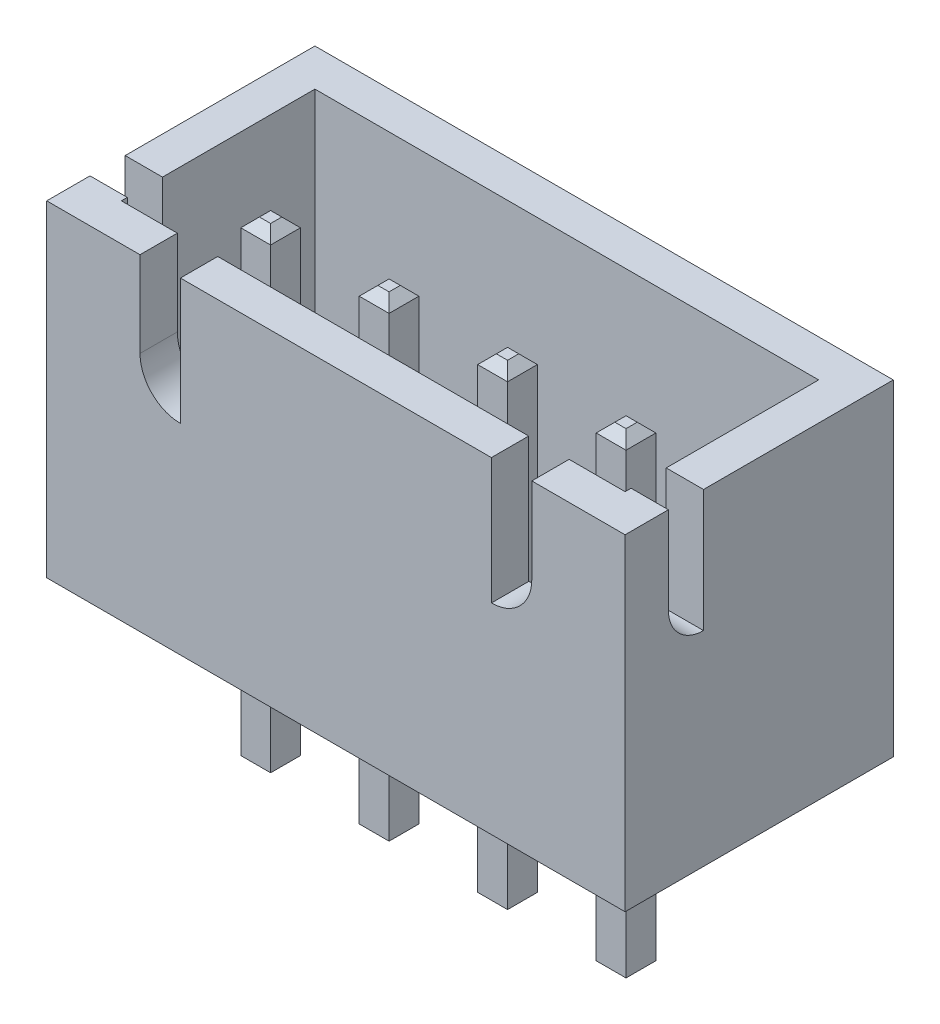
from build123d import *

# Parameters (mm, degrees)
SKETCH1_W                = 12.4
SKETCH1_H                = 5.75
BOSS_EXTRUDE1_DEPTH      = 7
SHELL1_T                 = -0.8
CUT_EXTRUDE1_DEPTH       = 13.4
CUT_EXTRUDE2_REACH       = 7.75
SKETCH4_W                = 0.64
SKETCH4_H                = 0.64
BOSS_EXTRUDE2_DEPTH      = 3.45
BOSS_EXTRUDE2_DEPTH_BACK = 6.75
CHAMFER1_SIZE            = 0.2


with BuildPart() as part:
    # Sketch1 → Boss-Extrude1 (new body)
    with BuildSketch(Plane(origin=(0, 0, 0), x_dir=(1, 0, 0), z_dir=(0, 1, 0))):
        Rectangle(SKETCH1_W, SKETCH1_H)
    extrude(amount=BOSS_EXTRUDE1_DEPTH)

    # Shell1
    shell1_openings = [part.faces().sort_by_distance(p)[0] for p in [
        (0, 7, 0),
    ]]
    offset(amount=SHELL1_T, openings=shell1_openings, kind=Kind.INTERSECTION)

    # Sketch2 → Cut-Extrude1 (cut, through all)
    with BuildSketch(Plane(origin=(6.2, 0, 0), x_dir=(0, 0, -1), z_dir=(1, 0, 0))):
        with BuildLine():
            Line((-1.19301282, 7), (-1.19301282, 4.379603984))
            ThreePointArc((-1.19301282, 4.379603984), (-1.72610374, 4.600417472), (-1.946917229, 5.133508392))
            Line((-1.946917229, 5.133508392), (-1.946917229, 7))
            Line((-1.946917229, 7), (-1.19301282, 7))
        make_face()
    extrude(amount=-CUT_EXTRUDE1_DEPTH, mode=Mode.SUBTRACT)

    # Sketch3 → Cut-Extrude2 (cut, up to next)
    with BuildSketch(Plane.XY.offset(2.875), mode=Mode.PRIVATE) as cut_extrude2_sk1:
        with BuildLine():
            Line((-4.2, 7), (-4.2, 6.728922615))
            Line((-4.2, 6.728922615), (-4.2, 5.166308225))
            ThreePointArc((-4.2, 5.166308225), (-3.946286554, 4.553789782), (-3.33376811, 4.300076336))
            Line((-3.33376811, 4.300076336), (-3.33376811, 7))
            Line((-3.33376811, 7), (-4.2, 7))
        make_face()
    cut_extrude2_tool1 = extrude(cut_extrude2_sk1.sketch, amount=-CUT_EXTRUDE2_REACH, mode=Mode.PRIVATE) & part.part
    add(cut_extrude2_tool1.solids().sort_by_distance((-3.749165, 5.735551, 2.875))[0], mode=Mode.SUBTRACT)
    # Sketch3 → Cut-Extrude2 (cut, up to next)
    with BuildSketch(Plane.XY.offset(2.875), mode=Mode.PRIVATE) as cut_extrude2_sk2:
        with BuildLine():
            Line((3.33376811, 7), (4.2, 7))
            Line((4.2, 7), (4.2, 6.728922615))
            Line((4.2, 6.728922615), (4.2, 5.166308225))
            ThreePointArc((4.2, 5.166308225), (3.946286554, 4.553789782), (3.33376811, 4.300076336))
            Line((3.33376811, 4.300076336), (3.33376811, 7))
        make_face()
    cut_extrude2_tool2 = extrude(cut_extrude2_sk2.sketch, amount=-CUT_EXTRUDE2_REACH, mode=Mode.PRIVATE) & part.part
    add(cut_extrude2_tool2.solids().sort_by_distance((3.749165, 5.735551, 2.875))[0], mode=Mode.SUBTRACT)

    # Sketch4 → Boss-Extrude2 (add, two sides)
    with BuildSketch(Plane.XZ) as boss_extrude2_sk:
        with Locations((-3.75, 0.525)):
            Rectangle(SKETCH4_W, SKETCH4_H)
        with Locations((-1.21, 0.525)):
            Rectangle(SKETCH4_W, SKETCH4_H)
        with Locations((1.33, 0.525)):
            Rectangle(SKETCH4_W, SKETCH4_H)
        with Locations((3.87, 0.525)):
            Rectangle(SKETCH4_W, SKETCH4_H)
    extrude(amount=BOSS_EXTRUDE2_DEPTH)
    extrude(boss_extrude2_sk.sketch, amount=-BOSS_EXTRUDE2_DEPTH_BACK)

    # Chamfer1
    chamfer1_edges = [part.edges().sort_by_distance(p)[0] for p in [
        (-1.21, 6.75, 0.205),
        (-1.53, 6.75, 0.525),
        (-1.21, 6.75, 0.845),
        (-0.89, 6.75, 0.525),
        (-1.21, -3.45, 0.205),
        (-0.89, -3.45, 0.525),
        (-1.21, -3.45, 0.845),
        (-1.53, -3.45, 0.525),
        (1.33, 6.75, 0.205),
        (1.01, 6.75, 0.525),
        (1.33, 6.75, 0.845),
        (1.65, 6.75, 0.525),
        (1.33, -3.45, 0.205),
        (1.65, -3.45, 0.525),
        (1.33, -3.45, 0.845),
        (1.01, -3.45, 0.525),
        (3.87, 6.75, 0.205),
        (3.55, 6.75, 0.525),
        (3.87, 6.75, 0.845),
        (4.19, 6.75, 0.525),
        (3.87, -3.45, 0.205),
        (4.19, -3.45, 0.525),
        (3.87, -3.45, 0.845),
        (3.55, -3.45, 0.525),
        (-3.43, 6.75, 0.525),
        (-3.75, 6.75, 0.205),
        (-4.07, 6.75, 0.525),
        (-3.75, 6.75, 0.845),
        (-3.43, -3.45, 0.525),
        (-3.75, -3.45, 0.845),
        (-4.07, -3.45, 0.525),
        (-3.75, -3.45, 0.205),
    ]]
    chamfer(chamfer1_edges, length=CHAMFER1_SIZE)


solid = part.part
